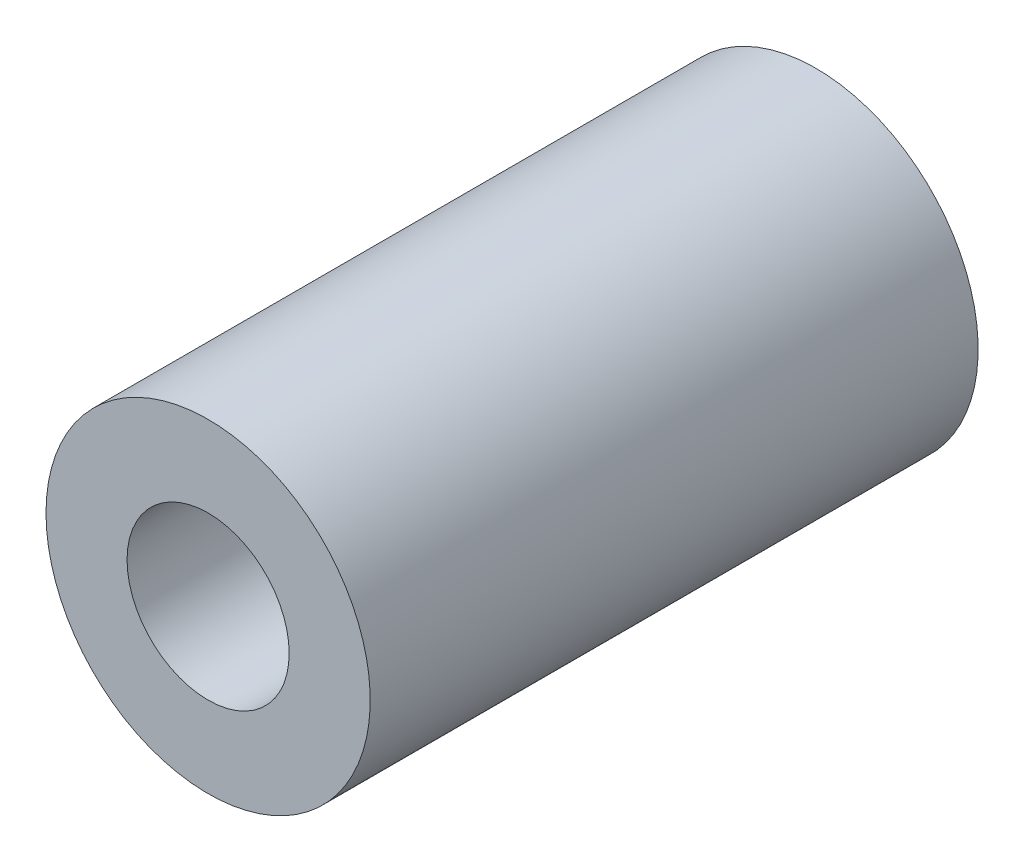
from build123d import *

# Parameters (mm, degrees)
SKETCH1_R           = 4
SKETCH1_R_2         = 2.00000381
BOSS_EXTRUDE1_DEPTH = 15


with BuildPart() as part:
    # Sketch1 → Boss-Extrude1 (new body)
    with BuildSketch(Plane(origin=(0, 0, 255.707141652), x_dir=(-1, 0, 0), z_dir=(0, 0, -1))):
        with Locations((-110.164644693, 149.062971337)):
            Circle(SKETCH1_R)
        with Locations((-110.164644693, 149.062971337)):
            Circle(SKETCH1_R_2, mode=Mode.SUBTRACT)
    extrude(amount=BOSS_EXTRUDE1_DEPTH)


solid = part.part
